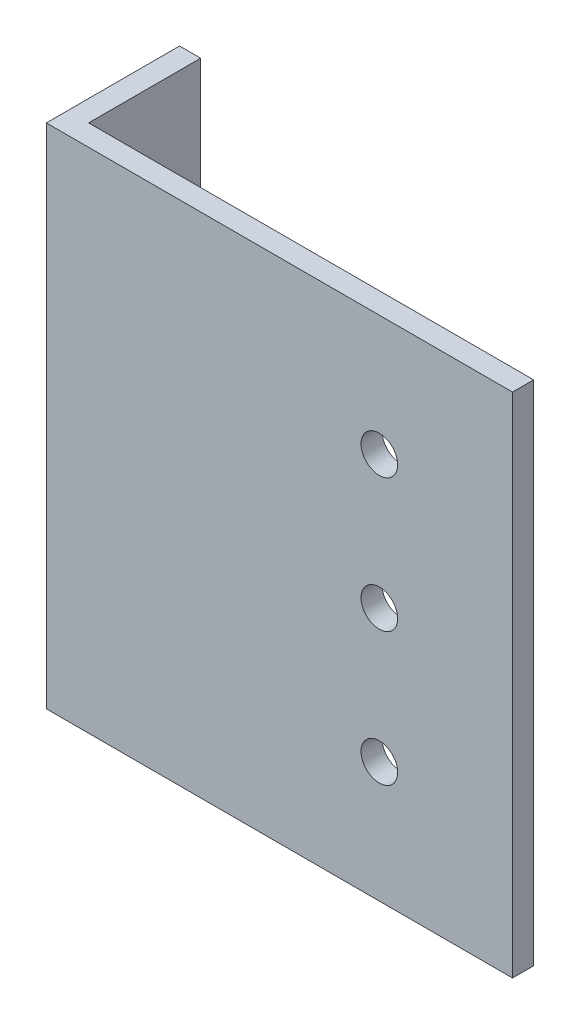
from build123d import *

# Parameters (mm, degrees)
EXTRUDE_THIN1_DEPTH  = 38.1
M5_CLEARANCE_HOLE1_D = 5.5
M5_CLEARANCE_HOLE2_D = 5.5


with BuildPart() as part:
    # Sketch1 → Extrude-Thin1 (new body, symmetric)
    with BuildSketch(Plane(origin=(0, 0, 0), x_dir=(1, 0, 0), z_dir=(0, 1, 0))):
        Polygon((0, 20), (0, 0), (70, 0), (70, 3.175), (3.175, 3.175), (3.175, 20), align=None)
    extrude(amount=EXTRUDE_THIN1_DEPTH, both=True)

    # M5 Clearance Hole1 (through all)
    with Locations(Plane.XY):
        with Locations((50, 20), (50, 0), (50, -20)):
            Hole(M5_CLEARANCE_HOLE1_D / 2)

    # M5 Clearance Hole2 (through all)
    with Locations(Plane(origin=(3.175, 0, 0), x_dir=(0, 0, -1), z_dir=(1, 0, 0))):
        with Locations((14, 20), (14, -20)):
            Hole(M5_CLEARANCE_HOLE2_D / 2)


solid = part.part
